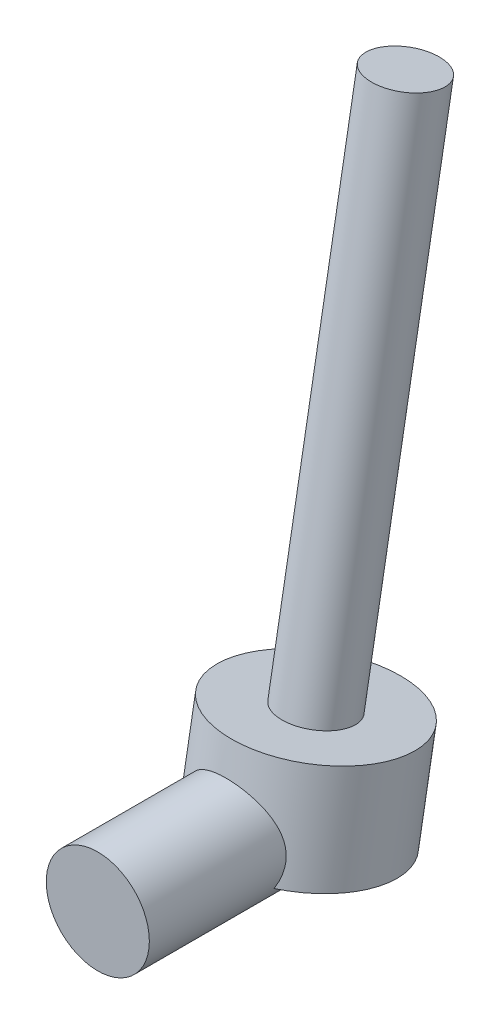
from build123d import *

# Parameters (mm, degrees)
SKETCH1_R                = 30
BOSS_EXTRUDE1_DEPTH      = 120
BOSS_EXTRUDE2_DEPTH      = 40
BOSS_EXTRUDE2_DEPTH_BACK = 20
SKETCH2_R                = 50
SKETCH3_R                = 20
BOSS_EXTRUDE3_DEPTH      = 300


with BuildPart() as part:
    # Sketch1 → Boss-Extrude1 (new body)
    with BuildSketch(Plane.XY):
        Circle(SKETCH1_R)
    extrude(amount=BOSS_EXTRUDE1_DEPTH)

    # Sketch2 → Boss-Extrude2 (add, two sides: drawn at the far end of the back side and taken through both)
    with BuildSketch(Plane(origin=(0, 0, 0), x_dir=(-1, 0, 0), z_dir=(0, 0.984807753012208, -0.17364817766693072)).offset(-BOSS_EXTRUDE2_DEPTH_BACK)):
        Circle(SKETCH2_R)
    extrude(amount=BOSS_EXTRUDE2_DEPTH + BOSS_EXTRUDE2_DEPTH_BACK)

    # Sketch3 → Boss-Extrude3 (add)
    with BuildSketch(Plane(origin=(0, 39.39231012, -6.945927107), x_dir=(1, 0, 0), z_dir=(0, 0.9848077530122081, -0.17364817766693072))):
        Circle(SKETCH3_R)
    extrude(amount=BOSS_EXTRUDE3_DEPTH)


solid = part.part
